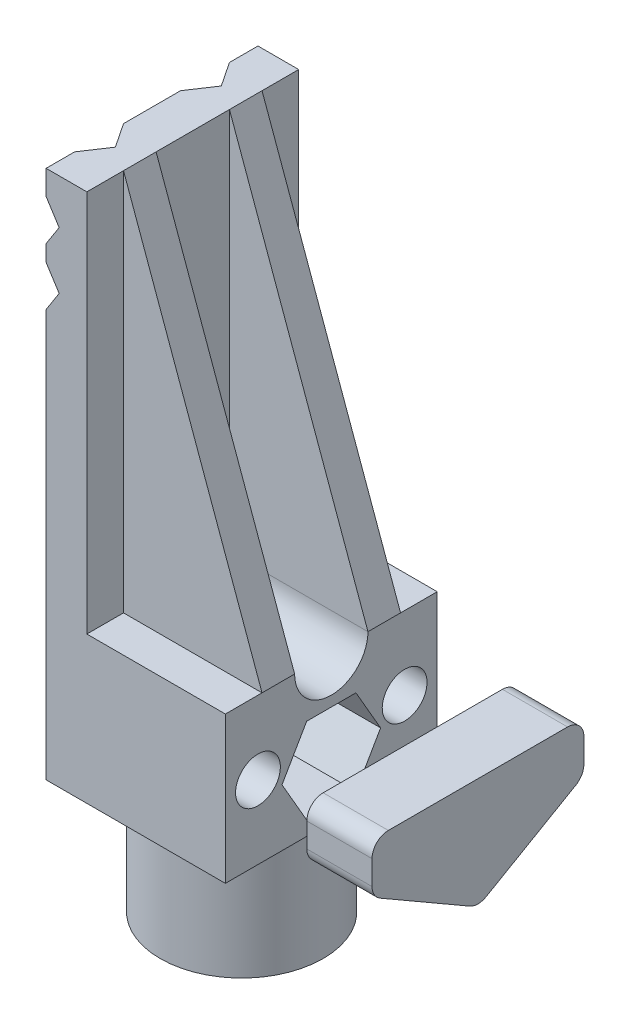
from build123d import *

# Parameters (mm, degrees)
SALIENTE_EXTRUIR1_DEPTH = 26
CROQUIS15_R             = 3.25
CORTAR_EXTRUIR5_DEPTH   = 28
SALIENTE_EXTRUIR3_DEPTH = 2
CROQUIS9_R              = 4.5
CORTAR_EXTRUIR1_DEPTH   = 17
CROQUIS10_R             = 2.75
CORTAR_EXTRUIR2_DEPTH   = 22
CORTAR_EXTRUIR3_DEPTH   = 50
SALIENTE_EXTRUIR5_DEPTH = 8
REDONDEO2_R             = 2
REDONDEO3_R             = 2
CROQUIS18_R             = 2.7
CROQUIS18_R_2           = 3.2
CORTAR_EXTRUIR6_DEPTH   = 6
CROQUIS19_R             = 10
CROQUIS19_R_2           = 3
SALIENTE_EXTRUIR6_DEPTH = 15
CORTAR_EXTRUIR7_DEPTH   = 10


with BuildPart() as part:
    # Croquis1 → Saliente-Extruir1 (new body)
    with BuildSketch(Plane.XY):
        Polygon((-24.80990609, 23.397347273), (-24.80990609, 21.397347273), (-23.20990609, 18.897347273), (-24.80990609, 16.397347273), (-24.80990609, -33.602652727), (-2.80990609, -33.602652727), (-2.80990609, -15.602652727), (-19.80990609, -15.602652727), (-19.80990609, 31.397347273), (-24.80990609, 31.397347273), (-24.80990609, 28.397347273), (-23.20990609, 25.897347273), align=None)
    extrude(amount=SALIENTE_EXTRUIR1_DEPTH)

    # Croquis15 → Cortar-Extruir5 (cut)
    with BuildSketch(Plane(origin=(-2.80990609, 0, 0), x_dir=(0, 0, -1), z_dir=(1, 0, 0))):
        with Locations((-13, -26.602652727)):
            Circle(CROQUIS15_R)
    extrude(amount=-CORTAR_EXTRUIR5_DEPTH, mode=Mode.SUBTRACT)

    # Croquis8 → Saliente-Extruir3 (add, symmetric)
    with BuildSketch(Plane(origin=(0, 0, 19.5), x_dir=(-1, 0, 0), z_dir=(0, 0, -1))):
        Polygon((19.80990609, 31.397347273), (19.80990609, -15.602652727), (2.80990609, -15.602652727), align=None)
    saliente_extruir3 = extrude(amount=SALIENTE_EXTRUIR3_DEPTH, both=True)

    # Simetría1: Saliente-Extruir3 across plane
    add(saliente_extruir3.mirror(Plane(origin=(0, 0, 13), x_dir=(1, 0, 0), z_dir=(0, 0, -1))))

    # Croquis9 → Cortar-Extruir1 (cut)
    with BuildSketch(Plane(origin=(-2.80990609, 0, 0), x_dir=(0, 0, -1), z_dir=(1, 0, 0))):
        with Locations((-13, -15.602652727)):
            Circle(CROQUIS9_R)
    extrude(amount=-CORTAR_EXTRUIR1_DEPTH, mode=Mode.SUBTRACT)

    # Croquis10 → Cortar-Extruir2 (cut)
    with BuildSketch(Plane(origin=(-2.80990609, 0, 0), x_dir=(0, 0, -1), z_dir=(1, 0, 0))):
        with Locations((-22, -24.602652727)):
            Circle(CROQUIS10_R)
        with Locations((-4, -24.602652727)):
            Circle(CROQUIS10_R)
    extrude(amount=-CORTAR_EXTRUIR2_DEPTH, mode=Mode.SUBTRACT)

    # Croquis12 → Cortar-Extruir3 (cut)
    with BuildSketch(Plane(origin=(0, 31.397347273, 0), x_dir=(1, 0, 0), z_dir=(0, 1, 0))):
        Polygon((-24.80990609, -22.5), (-24.80990609, -16.5), (-22.80990609, -19.5), align=None)
        Polygon((-22.80990609, -6.5), (-24.80990609, -3.5), (-24.80990609, -9.5), align=None)
    extrude(amount=-CORTAR_EXTRUIR3_DEPTH, mode=Mode.SUBTRACT)

    # Croquis19 → Saliente-Extruir6 (add)
    with BuildSketch(Plane.XZ.offset(33.602652727)):
        with Locations((-13.80990609, 13)):
            Circle(CROQUIS19_R)
        with Locations((-13.80990609, 13)):
            Circle(CROQUIS19_R_2, mode=Mode.SUBTRACT)
    extrude(amount=SALIENTE_EXTRUIR6_DEPTH)

    # Croquis21 → Cortar-Extruir7 (cut)
    with BuildSketch(Plane(origin=(-2.80990609, 0, 0), x_dir=(0, 0, -1), z_dir=(1, 0, 0))):
        Polygon((-9.975, -21.363199034), (-16.025, -21.363199034), (-19.05, -26.602652727), (-16.025, -31.84210642), (-9.975, -31.84210642), (-6.95, -26.602652727), align=None)
    extrude(amount=-CORTAR_EXTRUIR7_DEPTH, mode=Mode.SUBTRACT)


with BuildPart() as body_2:
    # Croquis17 → Saliente-Extruir5 (new body)
    with BuildSketch(Plane(origin=(7.19009391, 0, 0), x_dir=(0, 0, -1), z_dir=(1, 0, 0))):
        Polygon((-26, -19.976130017), (0, -19.976130017), (0, -26.099358276), (-13, -33.602652727), (-26, -26.099358276), align=None)
    extrude(amount=SALIENTE_EXTRUIR5_DEPTH)

    # Redondeo2
    redondeo2_edges = [body_2.edges().sort_by_distance(p)[0] for p in [
        (11.19009391, -33.602652727, 13),
    ]]
    fillet(redondeo2_edges, radius=REDONDEO2_R)

    # Redondeo3
    redondeo3_edges = [body_2.edges().sort_by_distance(p)[0] for p in [
        (11.19009391, -19.976130017, 26),
        (11.19009391, -19.976130017, 0),
        (11.19009391, -26.099358276, 0),
        (11.19009391, -26.099358276, 26),
    ]]
    fillet(redondeo3_edges, radius=REDONDEO3_R)

    # Croquis18 → Cortar-Extruir6 (cut)
    with BuildSketch(Plane(origin=(7.19009391, 0, 0), x_dir=(0, 0, -1), z_dir=(1, 0, 0))):
        with Locations((-22, -24.602652727)):
            Circle(CROQUIS18_R)
        with Locations((-13, -26.602652727)):
            Circle(CROQUIS18_R_2)
        with Locations((-4, -24.602652727)):
            Circle(CROQUIS18_R)
    extrude(amount=CORTAR_EXTRUIR6_DEPTH, mode=Mode.SUBTRACT)


solid = Compound([part.part, body_2.part])
